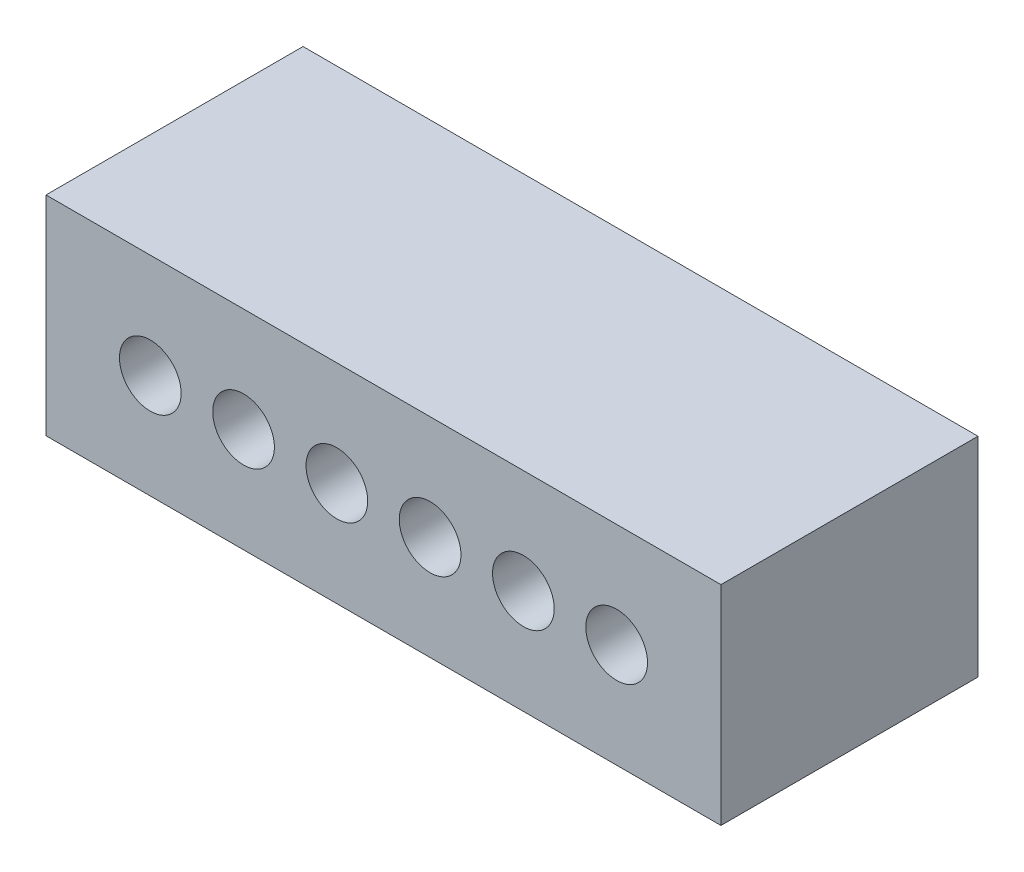
from build123d import *

# Parameters (mm, degrees)
SKETCH1_W           = 18.38
SKETCH1_H           = 5.68
SKETCH1_R           = 0.84
BOSS_EXTRUDE1_DEPTH = 7


with BuildPart() as part:
    # Sketch1 → Boss-Extrude1 (new body)
    with BuildSketch(Plane.XY):
        Rectangle(SKETCH1_W, SKETCH1_H)
        with Locations((-6.35, 0)):
            Circle(SKETCH1_R, mode=Mode.SUBTRACT)
        with Locations((-3.81, 0)):
            Circle(SKETCH1_R, mode=Mode.SUBTRACT)
        with Locations((-1.27, 0)):
            Circle(SKETCH1_R, mode=Mode.SUBTRACT)
        with Locations((1.27, 0)):
            Circle(SKETCH1_R, mode=Mode.SUBTRACT)
        with Locations((3.81, 0)):
            Circle(SKETCH1_R, mode=Mode.SUBTRACT)
        with Locations((6.35, 0)):
            Circle(SKETCH1_R, mode=Mode.SUBTRACT)
    extrude(amount=BOSS_EXTRUDE1_DEPTH)


solid = part.part
